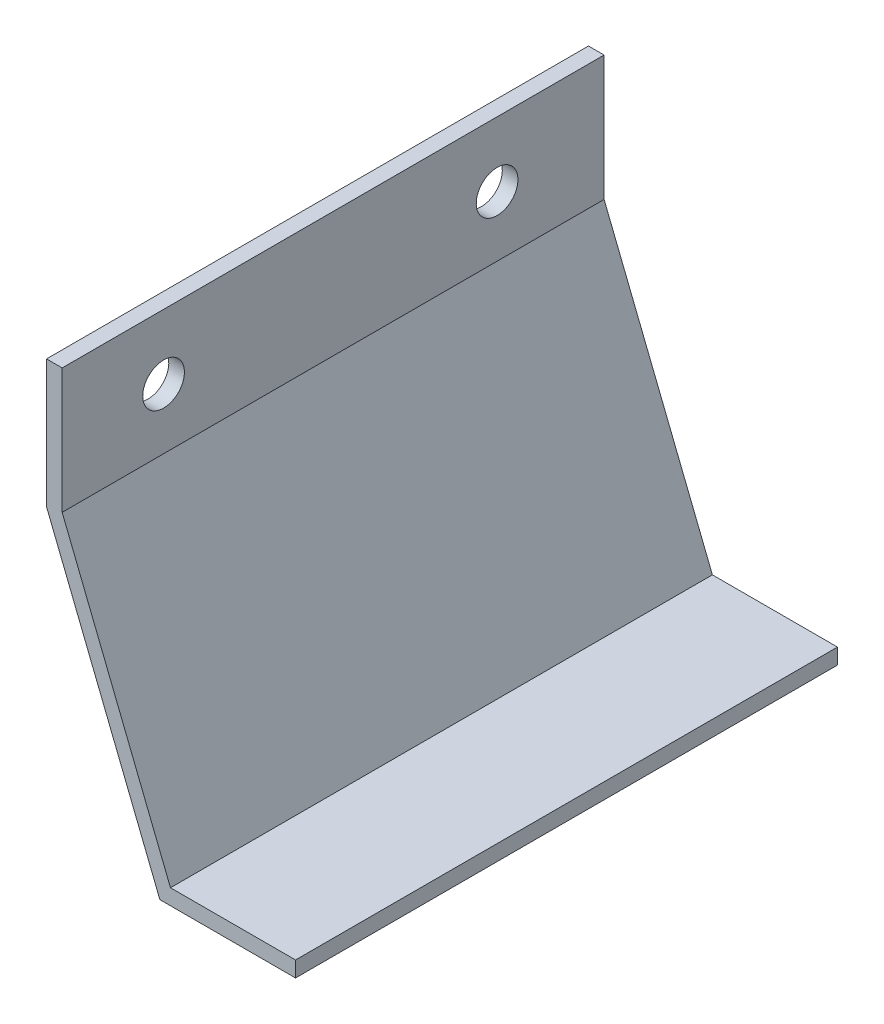
from build123d import *

# Parameters (mm, degrees)
EXTRUDE_THIN1_DEPTH = 165.1
SKETCH2_R           = 6.35
CUT_EXTRUDE1_DEPTH  = 5.7625


with BuildPart() as part:
    # Sketch1 → Extrude-Thin1 (new body)
    with BuildSketch(Plane.XY):
        Polygon((0, 120.65), (0, 82.55), (32.995567884, 0), (71.095567884, 0), (71.095567884, -4.7625), (29.770312185, -4.7625), (-4.7625, 81.633456448), (-4.7625, 120.65), align=None)
    extrude(amount=EXTRUDE_THIN1_DEPTH)

    # Sketch2 → Cut-Extrude1 (cut, through all)
    with BuildSketch(Plane(origin=(0, 0, 0), x_dir=(0, 0, -1), z_dir=(1, 0, 0))):
        with Locations((-134.204880657, 100.94227704)):
            Circle(SKETCH2_R)
        with Locations((-32.604880657, 100.94227704)):
            Circle(SKETCH2_R)
    extrude(amount=-CUT_EXTRUDE1_DEPTH, mode=Mode.SUBTRACT)


solid = part.part
